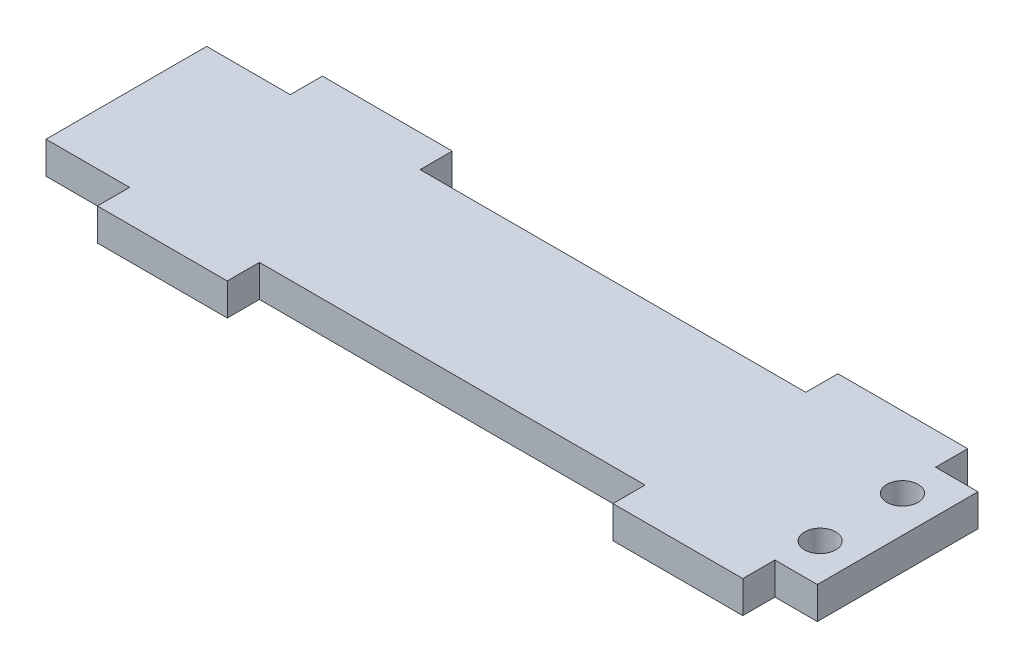
from build123d import *

# Parameters (mm, degrees)
SKETCH1_R           = 3.0861
BOSS_EXTRUDE1_DEPTH = 6.35


with BuildPart() as part:
    # Sketch1 → Boss-Extrude1 (new body)
    with BuildSketch(Plane(origin=(0, 0, 0), x_dir=(1, 0, 0), z_dir=(0, 1, 0))):
        Polygon((144.018, 0), (144.018, -6.35), (118.364, -6.35), (118.364, 0), (42.164, 0), (42.164, -6.35), (16.51, -6.35), (16.51, 0), (0, 0), (0, 31.75), (16.51, 31.75), (16.51, 38.1), (42.164, 38.1), (42.164, 31.75), (118.364, 31.75), (118.364, 38.1), (144.018, 38.1), (144.018, 31.75), (152.4, 31.75), (152.4, 0), align=None)
        with Locations((145.221541212, 7.744435671)):
            Circle(SKETCH1_R, mode=Mode.SUBTRACT)
        with Locations((145.221541212, 24.005564329)):
            Circle(SKETCH1_R, mode=Mode.SUBTRACT)
    extrude(amount=BOSS_EXTRUDE1_DEPTH)


solid = part.part
